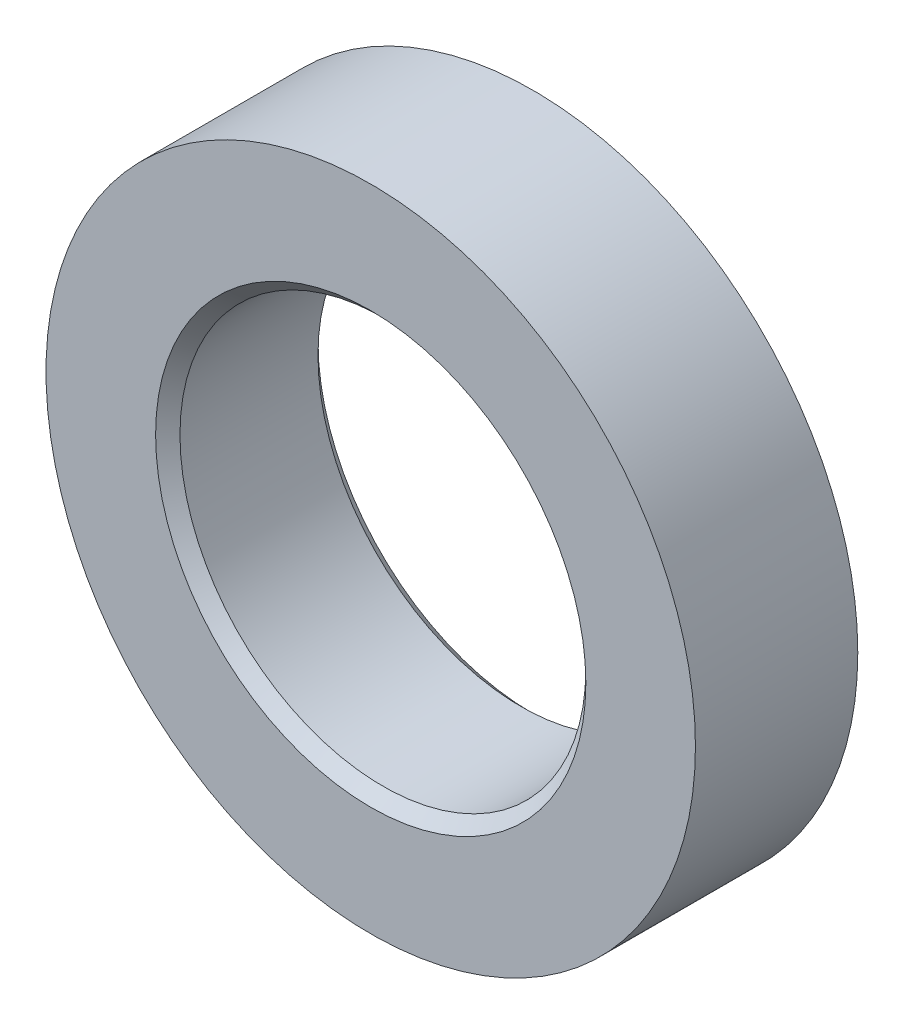
from build123d import *

# Parameters (mm, degrees)
SKETCH1_R           = 8
SKETCH1_R_2         = 5
BOSS_EXTRUDE1_DEPTH = 4
CHAMFER1_SIZE       = 0.3


with BuildPart() as part:
    # Sketch1 → Boss-Extrude1 (new body)
    with BuildSketch(Plane.XY):
        Circle(SKETCH1_R)
        Circle(SKETCH1_R_2, mode=Mode.SUBTRACT)
    extrude(amount=BOSS_EXTRUDE1_DEPTH)

    # Chamfer1
    chamfer1_edges = [part.edges().sort_by_distance(p)[0] for p in [
        (-5, 0, 0),
        (-5, 0, 4),
    ]]
    chamfer(chamfer1_edges, length=CHAMFER1_SIZE)


solid = part.part
